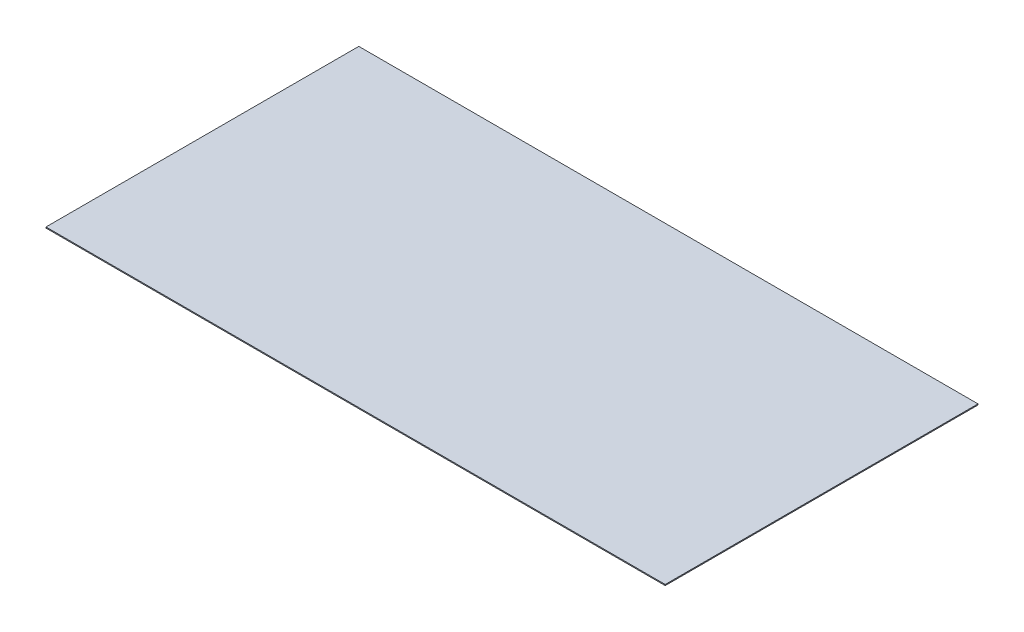
from build123d import *

# Parameters (mm, degrees)
SKETCH1_W           = 1956
SKETCH1_H           = 988
BOSS_EXTRUDE1_DEPTH = 3.2


with BuildPart() as part:
    # Sketch1 → Boss-Extrude1 (new body)
    with BuildSketch(Plane(origin=(0, 0, 0), x_dir=(1, 0, 0), z_dir=(0, 1, 0))):
        Rectangle(SKETCH1_W, SKETCH1_H)
    extrude(amount=BOSS_EXTRUDE1_DEPTH)


solid = part.part
